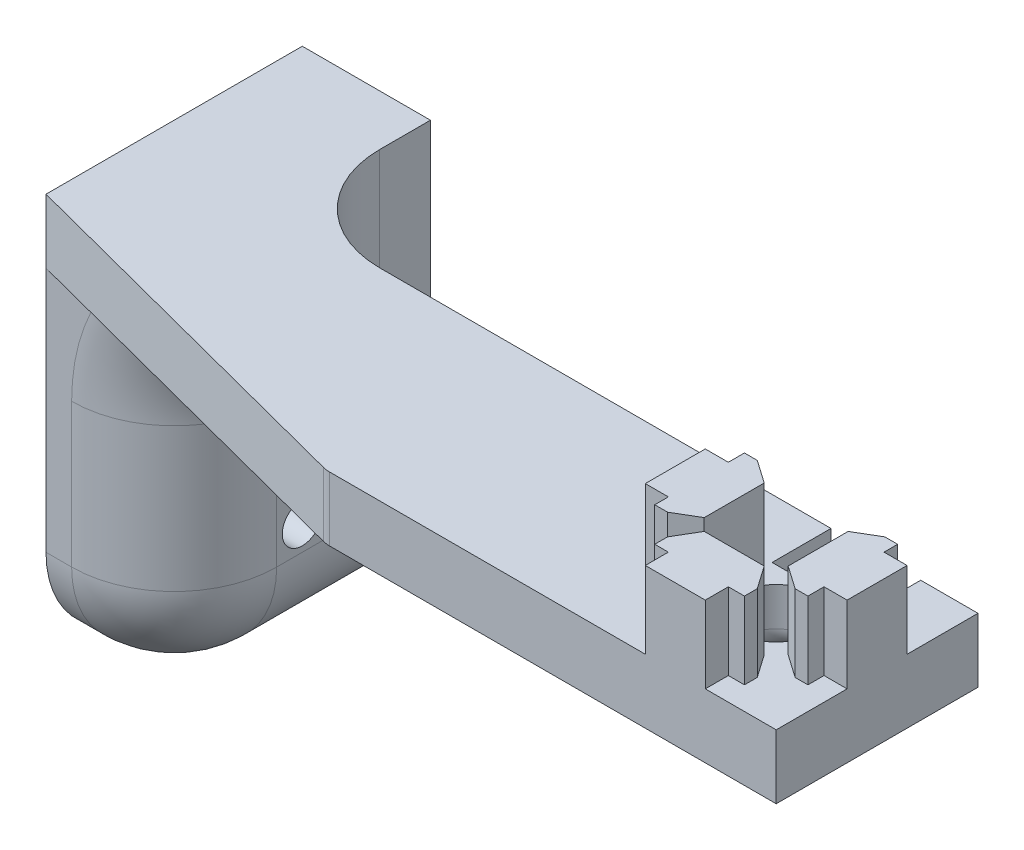
from build123d import *

# Parameters (mm, degrees)
BOSS_EXTRUDE1_DEPTH   = 7.62
BOSS_EXTRUDE1_2_DEPTH = 7.62
BOSS_EXTRUDE1_3_DEPTH = 7.62
BOSS_EXTRUDE1_4_DEPTH = 7.62
SKETCH2_W             = 82.1538108
SKETCH2_H             = 20
BOSS_EXTRUDE2_DEPTH   = 6.35
CUT_EXTRUDE1_DEPTH    = 75.17097352
FILLET1_R             = 2.54
SKETCH13_R            = 3.5
CUT_EXTRUDE5_DEPTH    = 74.240950383
FILLET6_R             = 2.54
SKETCH14_W            = 8.89
SKETCH14_H            = 5.842
CUT_EXTRUDE6_DEPTH    = 75.17097352
SKETCH15_W            = 25.4
SKETCH15_H            = 40.894
BOSS_EXTRUDE3_DEPTH   = 12.7
FILLET15_R            = 10.16
FILLET16_R            = 10.16
FILLET17_R            = 10.16
FILLET18_R            = 10.16
SKETCH18_R            = 1.984375
CUT_EXTRUDE9_DEPTH    = 12.7


with BuildPart() as part:
    # Sketch1 → Boss-Extrude1 (new body)
    with BuildSketch(Plane(origin=(0, 0, 0), x_dir=(1, 0, 0), z_dir=(0, 1, 0))):
        Polygon((2.9718, 10), (-2.9718, 10), (-2.9718, 7.714), (-4.567901235, 7.714), (-4.567901235, 6.444), (-2.9718, 4.158), (2.9718, 4.158), (4.322098765, 6.444), (4.322098765, 7.714), (2.9718, 7.714), align=None)
    extrude(amount=BOSS_EXTRUDE1_DEPTH)



with BuildPart() as body_2:
    # Sketch1 → Boss-Extrude1 2 (new body)
    with BuildSketch(Plane(origin=(0, 0, 0), x_dir=(1, 0, 0), z_dir=(0, 1, 0))):
        Polygon((4.158, -2.9718), (4.158, 2.9718), (6.444, 4.322098765), (7.714, 4.322098765), (7.714, 2.9718), (10, 2.9718), (10, -2.9718), (7.714, -2.9718), (7.714, -4.567901235), (6.444, -4.567901235), align=None)
    extrude(amount=BOSS_EXTRUDE1_2_DEPTH)


with BuildPart() as body_3:
    # Sketch1 → Boss-Extrude1 3 (new body)
    with BuildSketch(Plane(origin=(0, 0, 0), x_dir=(1, 0, 0), z_dir=(0, 1, 0))):
        Polygon((-10, -2.9718), (-10, 2.9718), (-7.714, 2.9718), (-7.714, 4.567901235), (-6.444, 4.567901235), (-4.158, 2.9718), (-4.158, -2.9718), (-6.444, -4.322098765), (-7.714, -4.322098765), (-7.714, -2.9718), align=None)
    extrude(amount=BOSS_EXTRUDE1_3_DEPTH)


with BuildPart() as body_4:
    # Sketch1 → Boss-Extrude1 4 (new body)
    with BuildSketch(Plane(origin=(0, 0, 0), x_dir=(1, 0, 0), z_dir=(0, 1, 0))):
        Polygon((4.567901235, -6.444), (2.9718, -4.158), (-2.9718, -4.158), (-4.322098765, -6.444), (-4.322098765, -7.714), (-2.9718, -7.714), (-2.9718, -10), (2.9718, -10), (2.9718, -7.714), (4.567901235, -7.714), align=None)
    extrude(amount=BOSS_EXTRUDE1_4_DEPTH)


with BuildPart() as part_1:
    add(part.part)

    add(body_2.part)  # Boss-Extrude2 merges body 2

    add(body_3.part)  # Boss-Extrude2 merges body 3

    add(body_4.part)  # Boss-Extrude2 merges body 4
    # Sketch2 → Boss-Extrude2 (add)
    with BuildSketch(Plane.XZ):
        with Locations((-31.0769054, 0)):
            Rectangle(SKETCH2_W, SKETCH2_H)
    extrude(amount=BOSS_EXTRUDE2_DEPTH)

    # Sketch4 → Cut-Extrude1 (cut, through all)
    with BuildSketch(Plane(origin=(0, -6.35, 0), x_dir=(-1, 0, 0), z_dir=(0, -1, 0))):
        Polygon((72.1538108, -10), (34.6126108, -10), (72.1538108, -0.2108), align=None)
    extrude(amount=-CUT_EXTRUDE1_DEPTH, mode=Mode.SUBTRACT)

    # Fillet1
    fillet1_edges = [part_1.edges().sort_by_distance(p)[0] for p in [
        (-34.6126108, -3.175, 10),
    ]]
    fillet(fillet1_edges, radius=FILLET1_R)

    # Sketch13 → Cut-Extrude5 (cut, through all)
    with BuildSketch(Plane(origin=(0, 0, 0), x_dir=(1, 0, 0), z_dir=(0, 1, 0))):
        with Locations(Location((0, 0, 0), (0, 0, 270))):
            Circle(SKETCH13_R)
    extrude(amount=-CUT_EXTRUDE5_DEPTH, mode=Mode.SUBTRACT)

    # Fillet6
    fillet6_edges = [part_1.edges().sort_by_distance(p)[0] for p in [
        (0, -6.35, -3.5),
    ]]
    fillet(fillet6_edges, radius=FILLET6_R)

    # Sketch14 → Cut-Extrude6 (cut, through all)
    with BuildSketch(Plane(origin=(0, 7.62, 0), x_dir=(1, 0, 0), z_dir=(0, 1, 0))):
        with Locations((-0.122901235, 7.079)):
            Rectangle(SKETCH14_W, SKETCH14_H)
    extrude(amount=-CUT_EXTRUDE6_DEPTH, mode=Mode.SUBTRACT)

    # Sketch15 → Boss-Extrude3 (add)
    with BuildSketch(Plane.ZY.offset(72.1538108)):
        with Locations((-12.4892, -20.447)):
            Rectangle(SKETCH15_W, SKETCH15_H)
    extrude(amount=-BOSS_EXTRUDE3_DEPTH)

    # Fillet15
    fillet15_edges = [part_1.edges().sort_by_distance(p)[0] for p in [
        (-59.4538108, -6.35, -4.8946),
    ]]
    fillet(fillet15_edges, radius=FILLET15_R)

    # Fillet16
    fillet16_edges = [part_1.edges().sort_by_distance(p)[0] for p in [
        (-59.4538108, -8.255, -10),
    ]]
    fillet(fillet16_edges, radius=FILLET16_R)

    # Fillet17
    fillet17_edges = [part_1.edges().sort_by_distance(p)[0] for p in [
        (-59.4538108, -40.894, -12.4892),
    ]]
    fillet(fillet17_edges, radius=FILLET17_R)

    # Fillet18
    fillet18_edges = [part_1.edges().sort_by_distance(p)[0] for p in [
        (-56.478015697, -9.325795103, 0.2108),
        (-70.8838108, -40.894, 0.2108),
        (-59.4538108, -23.622, 0.2108),
        (-62.429605903, -37.918204897, 0.2108),
    ]]
    fillet(fillet18_edges, radius=FILLET18_R)

    # Sketch18 → Cut-Extrude9 (cut)
    with BuildSketch(Plane.ZY.offset(72.1538108)):
        with Locations((-12.4892, -28.194)):
            Circle(SKETCH18_R)
    extrude(amount=-CUT_EXTRUDE9_DEPTH, mode=Mode.SUBTRACT)


solid = part_1.part
